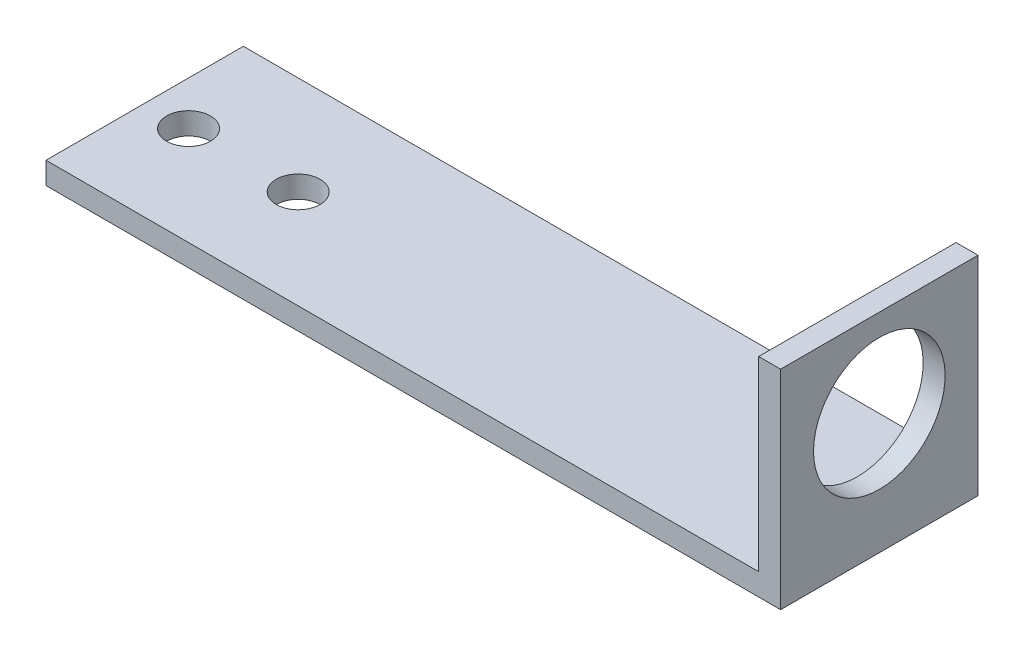
from build123d import *

# Parameters (mm, degrees)
BOSS_EXTRUDE1_DEPTH = 18
CUT_EXTRUDE1_REACH  = 4
SKETCH2_R           = 6
CUT_EXTRUDE2_REACH  = 4
SKETCH3_R           = 2


with BuildPart() as part:
    # Sketch1 → Boss-Extrude1 (new body)
    with BuildSketch(Plane.XY):
        Polygon((0, 0), (0, 19), (-2, 19), (-2, 2), (-67, 2), (-67, 0), align=None)
    extrude(amount=BOSS_EXTRUDE1_DEPTH)

    # Sketch2 → Cut-Extrude1 (cut, up to next)
    with BuildSketch(Plane.ZY.offset(2), mode=Mode.PRIVATE) as cut_extrude1_sk1:
        with Locations((9, 11)):
            Circle(SKETCH2_R)
    cut_extrude1_tool1 = extrude(cut_extrude1_sk1.sketch, amount=-CUT_EXTRUDE1_REACH, mode=Mode.PRIVATE) & part.part
    add(cut_extrude1_tool1.solids().sort_by_distance((-2, 11, 9))[0], mode=Mode.SUBTRACT)

    # Sketch3 → Cut-Extrude2 (cut, up to next)
    with BuildSketch(Plane(origin=(0, 2, 0), x_dir=(1, 0, 0), z_dir=(0, 1, 0)), mode=Mode.PRIVATE) as cut_extrude2_sk1:
        with Locations((-63, -9)):
            Circle(SKETCH3_R)
    cut_extrude2_tool1 = extrude(cut_extrude2_sk1.sketch, amount=-CUT_EXTRUDE2_REACH, mode=Mode.PRIVATE) & part.part
    add(cut_extrude2_tool1.solids().sort_by_distance((-63, 2, 9))[0], mode=Mode.SUBTRACT)
    # Sketch3 → Cut-Extrude2 (cut, up to next)
    with BuildSketch(Plane(origin=(0, 2, 0), x_dir=(1, 0, 0), z_dir=(0, 1, 0)), mode=Mode.PRIVATE) as cut_extrude2_sk2:
        with Locations((-53, -9)):
            Circle(SKETCH3_R)
    cut_extrude2_tool2 = extrude(cut_extrude2_sk2.sketch, amount=-CUT_EXTRUDE2_REACH, mode=Mode.PRIVATE) & part.part
    add(cut_extrude2_tool2.solids().sort_by_distance((-53, 2, 9))[0], mode=Mode.SUBTRACT)


solid = part.part
